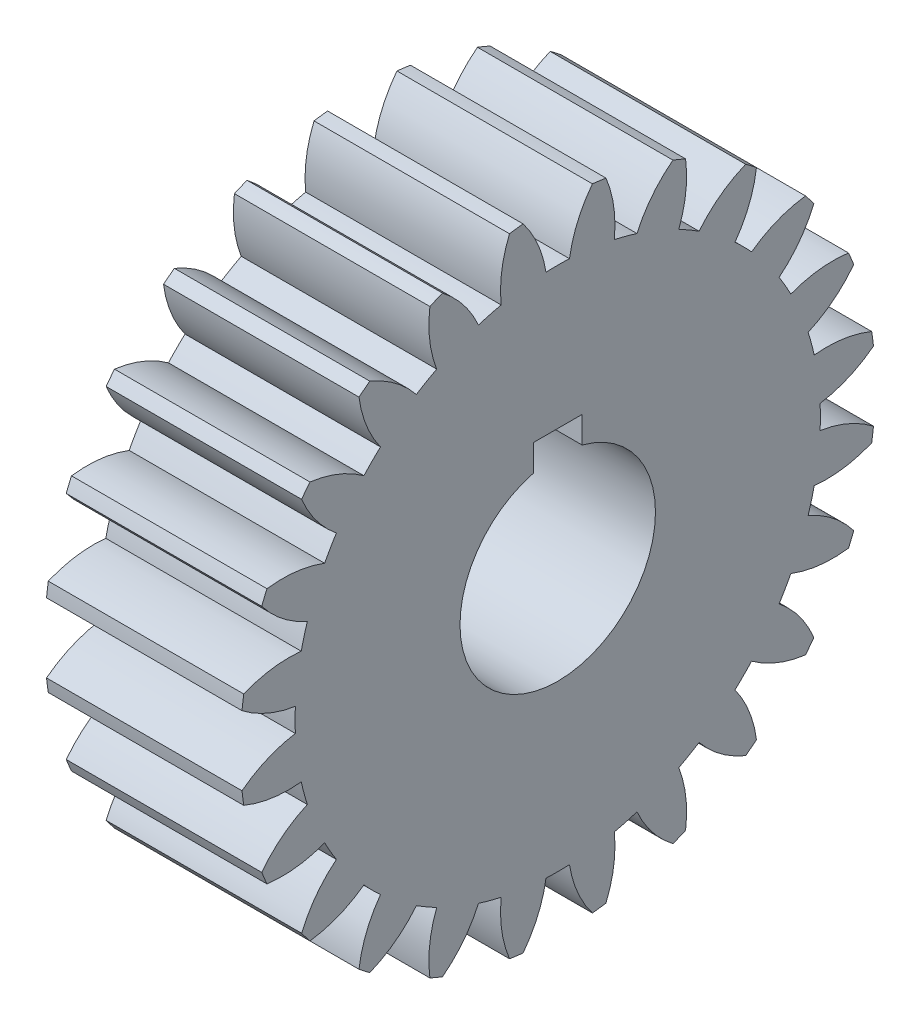
from build123d import *

# Parameters (mm, degrees)
BASPROSKE_W             = 12.7
BASPROSKE_H             = 20.6375
TOOTHCUT_DEPTH          = 32.829276029
TEETHCUTS_COUNT         = 24
BORSKE_R                = 6.35
BORE_DEPTH              = 50.8000508
KEYSKE_W                = 3.175
KEYSKE_H                = 7.4676
KEYWAY_DEPTH            = 50.8000508
SKETCH1_W               = 3.175
SKETCH1_H               = 0.4064
CUT_EXTRUDE3_DEPTH      = 32.669469117
CUT_EXTRUDE3_DEPTH_BACK = 32.669469117


with BuildPart() as part:
    # BasProSke → Base-Revolve (revolve)
    with BuildSketch(Plane(origin=(0, 0, 0), x_dir=(1, 0, 0), z_dir=(0, 1, 0)), mode=Mode.PRIVATE) as base_revolve_sk:
        with Locations((6.35, 10.31875)):
            Rectangle(BASPROSKE_W, BASPROSKE_H)
    revolve(base_revolve_sk.sketch.rotate(Axis((-10, 0, 0), (1, 0, 0)), 180), axis=Axis((-10, 0, 0), (1, 0, 0)))

    # TooCutSke → ToothCut (cut, through all)
    with BuildSketch(Plane(origin=(0, 0, 0), x_dir=(0, 0, -1), z_dir=(1, 0, 0))):
        with BuildLine():
            ThreePointArc((0.762542858, 17.047308877), (0, 17.064355), (-0.762542858, 17.047308877))
            ThreePointArc((-0.762542858, 17.047308877), (-1.295412414, 18.888113288), (-2.270705673, 20.537753824))
            ThreePointArc((-2.270705673, 20.537753824), (0, 20.6629), (2.270705673, 20.537753824))
            ThreePointArc((2.270705673, 20.537753824), (1.295412414, 18.888113288), (0.762542858, 17.047308877))
        make_face()
    toothcut = extrude(amount=TOOTHCUT_DEPTH, mode=Mode.SUBTRACT)

    # TeethCuts: ToothCut ×24 about axis
    teethcuts_axis = Axis((0, 0, 0), (1, 0, 0))
    for i in range(1, TEETHCUTS_COUNT):
        add(toothcut.rotate(teethcuts_axis, i * 360 / TEETHCUTS_COUNT), mode=Mode.SUBTRACT)

    # BorSke → Bore (cut, symmetric)
    with BuildSketch(Plane(origin=(0, 0, 0), x_dir=(0, 0, -1), z_dir=(1, 0, 0))):
        with Locations(Location((0, 0, 0), (0, 0, 180))):
            Circle(BORSKE_R)
    extrude(amount=BORE_DEPTH, both=True, mode=Mode.SUBTRACT)

    # KeySke → Keyway (cut, symmetric)
    with BuildSketch(Plane(origin=(0, 0, 0), x_dir=(0, 0, -1), z_dir=(1, 0, 0))):
        with Locations((0, 3.7338)):
            Rectangle(KEYSKE_W, KEYSKE_H)
    extrude(amount=KEYWAY_DEPTH, both=True, mode=Mode.SUBTRACT)

    # Sketch1 → Cut-Extrude3 (cut, two sides)
    with BuildSketch(Plane(origin=(12.7, 0, 0), x_dir=(0, 0, -1), z_dir=(1, 0, 0))) as cut_extrude3_sk:
        with Locations((0, 7.6708)):
            Rectangle(SKETCH1_W, SKETCH1_H)
    extrude(amount=CUT_EXTRUDE3_DEPTH, mode=Mode.SUBTRACT)
    extrude(cut_extrude3_sk.sketch, amount=-CUT_EXTRUDE3_DEPTH_BACK, mode=Mode.SUBTRACT)


solid = part.part
